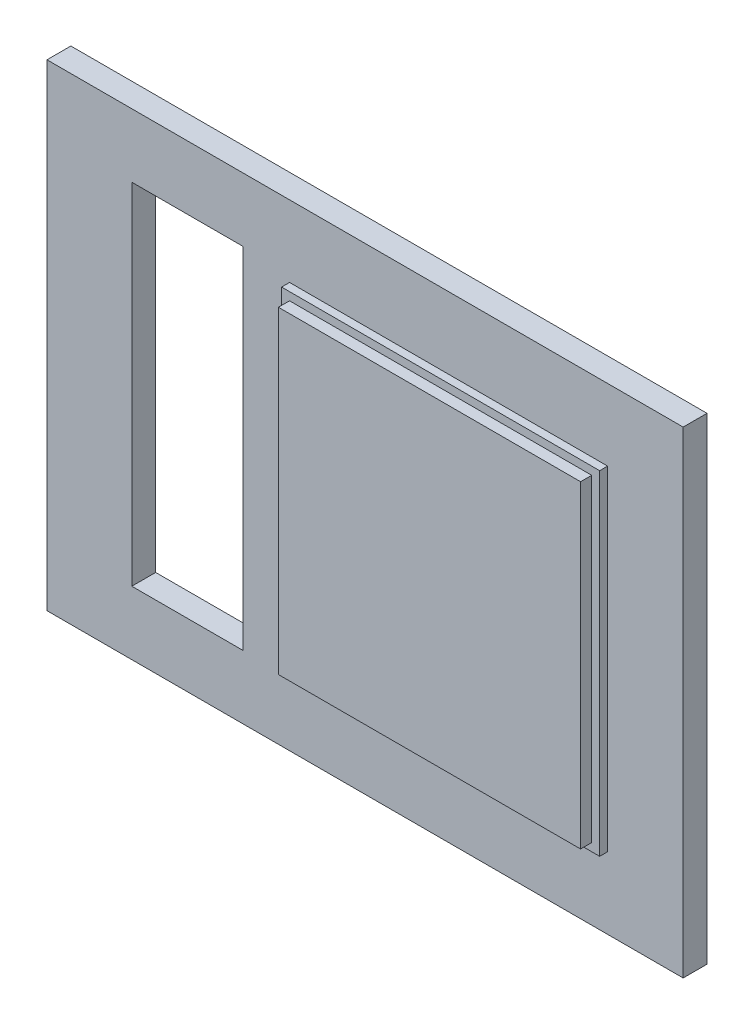
from build123d import *

# Parameters (mm, degrees)
SKETCH1_W           = 40
SKETCH1_H           = 30
BOSS_EXTRUDE1_DEPTH = 1.5
SKETCH2_W           = 20
SKETCH2_H           = 21
BOSS_EXTRUDE2_DEPTH = 0.5
SKETCH4_W           = 19
SKETCH4_H           = 20
BOSS_EXTRUDE3_DEPTH = 0.7
SKETCH5_W           = 7
SKETCH5_H           = 22
CUT_EXTRUDE1_DEPTH  = 1.5


with BuildPart() as part:
    # Sketch1 → Boss-Extrude1 (new body)
    with BuildSketch(Plane.XY):
        Rectangle(SKETCH1_W, SKETCH1_H)
    extrude(amount=BOSS_EXTRUDE1_DEPTH)

    # Sketch2 → Boss-Extrude2 (add)
    with BuildSketch(Plane.XY.offset(1.5)):
        with Locations((5.25, 0)):
            Rectangle(SKETCH2_W, SKETCH2_H)
    extrude(amount=BOSS_EXTRUDE2_DEPTH)

    # Sketch4 → Boss-Extrude3 (add)
    with BuildSketch(Plane.XY.offset(2)):
        with Locations((5.25, 0)):
            Rectangle(SKETCH4_W, SKETCH4_H)
    extrude(amount=BOSS_EXTRUDE3_DEPTH)

    # Sketch5 → Cut-Extrude1 (cut)
    with BuildSketch(Plane.XY.offset(1.5)):
        with Locations((-11.166666, 0)):
            Rectangle(SKETCH5_W, SKETCH5_H)
    extrude(amount=-CUT_EXTRUDE1_DEPTH, mode=Mode.SUBTRACT)


solid = part.part
